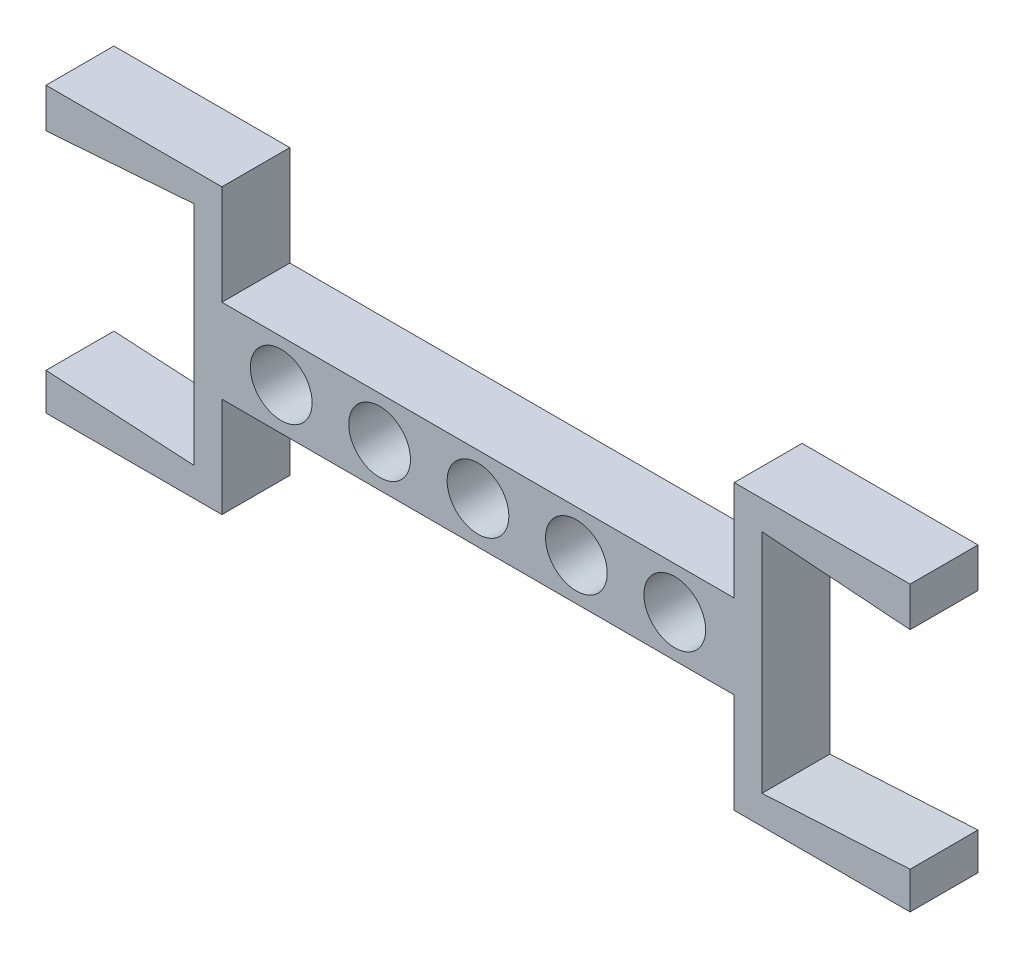
from build123d import *

# Parameters (mm, degrees)
SKETCH_1_R      = 2.5
SKETCH_1_W      = 14.25
SKETCH_1_H      = 1.5
EXTRUDE_2_DEPTH = 5.5


with BuildPart() as part:
    # 草圖1 → 填料-伸長2 (new body)
    with BuildSketch(Plane.XY):
        Polygon((-70.969139755, -35.192052365), (-85.219139755, -35.192052365), (-85.219139755, -35.633297351), (-85.219139755, -36.892052365), (-73.216342126, -36.014419398), (-73.216342126, -54.369685333), (-85.219139755, -53.692052365), (-85.219139755, -54.75080738), (-85.219139755, -55.192052365), (-85.219139755, -56.692052365), (-70.969139755, -56.692052365), (-70.969139755, -55.192052365), (-70.969139755, -48.592052365), (-66.164139755, -48.592052365), (-29.469139755, -48.592052365), (-29.469139755, -55.192052365), (-29.469139755, -56.692052365), (-15.219139755, -56.692052365), (-15.219139755, -55.192052365), (-15.219139755, -54.75080738), (-15.219139755, -53.692052365), (-27.221937385, -54.369685333), (-27.221937385, -36.014419398), (-15.219139755, -36.892052365), (-15.219139755, -35.633297351), (-15.219139755, -35.192052365), (-15.219139755, -33.692052365), (-29.469139755, -33.692052365), (-29.469139755, -35.192052365), (-29.469139755, -41.792052365), (-66.164139755, -41.792052365), (-70.969139755, -41.792052365), align=None)
        with Locations((-66.164139755, -45.192052365)):
            Circle(SKETCH_1_R, mode=Mode.SUBTRACT)
        with Locations((-58.194139755, -45.192052365)):
            Circle(SKETCH_1_R, mode=Mode.SUBTRACT)
        with Locations((-50.224139755, -45.192052365)):
            Circle(SKETCH_1_R, mode=Mode.SUBTRACT)
        with Locations((-42.254139755, -45.192052365)):
            Circle(SKETCH_1_R, mode=Mode.SUBTRACT)
        with Locations((-34.284139755, -45.192052365)):
            Circle(SKETCH_1_R, mode=Mode.SUBTRACT)
        with Locations((-78.094139755, -34.442052365)):
            Rectangle(SKETCH_1_W, SKETCH_1_H)
    extrude(amount=EXTRUDE_2_DEPTH)


solid = part.part
